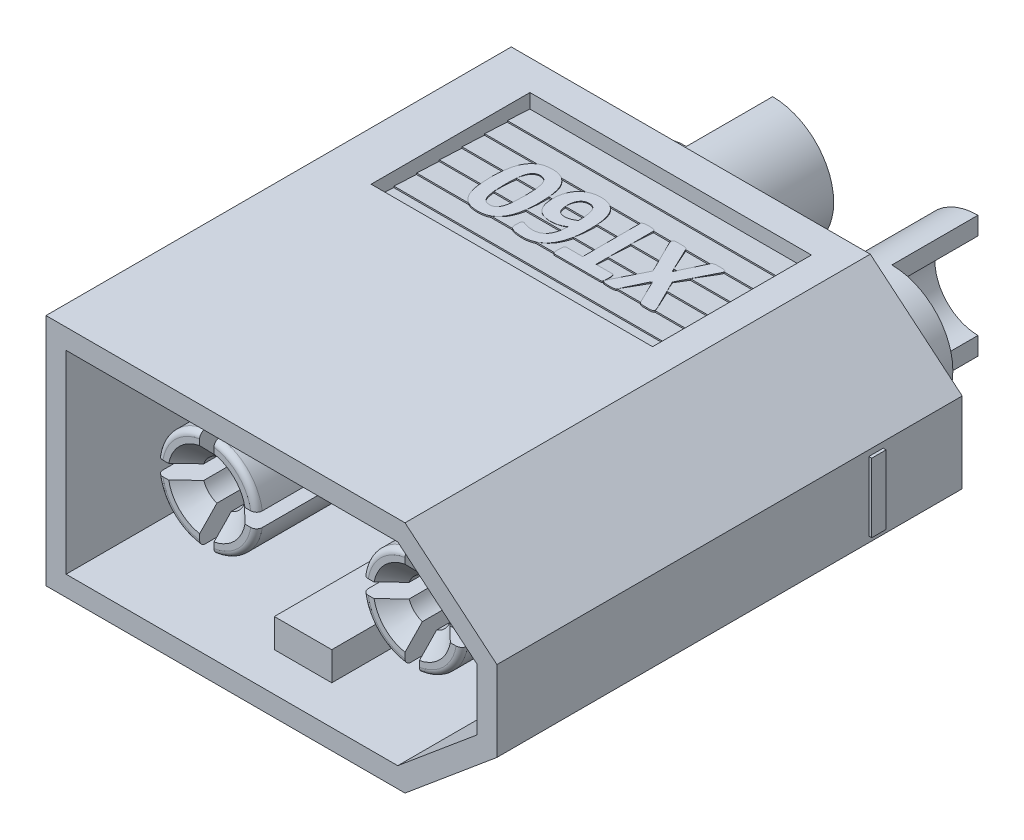
from build123d import *

# Parameters (mm, degrees)
RESSALTO_EXTRUS_O1_DEPTH       = 16.2
CORTE_EXTRUS_O1_DEPTH          = 9.3
ESBO_O3_W                      = 0.5
ESBO_O3_H                      = 2.4
RESSALTO_EXTRUS_O2_DEPTH       = 0.1
RESSALTO_EXTRUS_O2_DEPTH_BACK  = 15.8
ESBO_O4_W                      = 2.4
ESBO_O4_H                      = 0.5
RESSALTO_EXTRUS_O3_DEPTH       = 0.1
ESBO_O5_R                      = 2.925
CORTE_EXTRUS_O2_DEPTH          = 3.5
ESBO_O6_R                      = 2.125
CORTE_EXTRUS_O3_DEPTH          = 21.676934613
ESBO_O7_R                      = 2.125
RESSALTO_EXTRUS_O4_DEPTH       = 5
RESSALTO_EXTRUS_O4_DEPTH_BACK  = 7.1
FURO_DE_DI_METRO_3_0_3_1_D     = 3
FURO_DE_DI_METRO_3_0_3_1_DEPTH = 9
FURO_DE_DI_METRO_3_0_3_1_TIP   = 0.901290929
ESBO_O10_W                     = 2.125
ESBO_O10_H                     = 3
CORTE_EXTRUS_O4_DEPTH          = 28.667715844
RESSALTO_EXTRUS_O5_DEPTH       = 7.6
FILETE1_R                      = 0.2
CHANFRO1_SIZE                  = 0.6
CORTE_EXTRUS_O5_START          = -1.7
CORTE_EXTRUS_O5_DEPTH          = 9.8
RESSALTO_EXTRUS_O6_DEPTH       = 0.05
RESSALTO_EXTRUS_O7_DEPTH       = 0.05
ESBO_O15_W                     = 2
ESBO_O15_H                     = 1
RESSALTO_EXTRUS_O8_DEPTH       = 7.95
ESBO_O16_W                     = 1.1
ESBO_O16_H                     = 4.1
CORTE_EXTRUS_O6_DEPTH          = 1


with BuildPart() as part:
    # Esboço1 → Ressalto-extrusão1 (new body)
    with BuildSketch(Plane.XY):
        Polygon((0, 0), (0, 4.075), (12.5, 4.075), (15.7, 1.4), (15.7, -1.4), (12.5, -4.075), (0, -4.075), align=None)
    extrude(amount=-RESSALTO_EXTRUS_O1_DEPTH)

    # Esboço2 → Corte-extrusão1 (cut)
    with BuildSketch(Plane.XY):
        Polygon((0.7, 3.375), (0.7, -3.375), (12.245957236, -3.375), (15, -1.072792377), (15, 1.072792377), (12.245957236, 3.375), align=None)
    extrude(amount=-CORTE_EXTRUS_O1_DEPTH, mode=Mode.SUBTRACT)

    # Esboço3 → Ressalto-extrusão2 (add, two sides)
    with BuildSketch(Plane(origin=(15.7, 0, 0), x_dir=(0, 0, -1), z_dir=(1, 0, 0))) as ressalto_extrus_o2_sk:
        with Locations((13.2, 0)):
            Rectangle(ESBO_O3_W, ESBO_O3_H)
    extrude(amount=RESSALTO_EXTRUS_O2_DEPTH)
    extrude(ressalto_extrus_o2_sk.sketch, amount=-RESSALTO_EXTRUS_O2_DEPTH_BACK)

    # Esboço4 → Ressalto-extrusão3 (add)
    with BuildSketch(Plane.ZY):
        with Locations((-13.2, 0)):
            Rectangle(ESBO_O4_W, ESBO_O4_H)
    extrude(amount=RESSALTO_EXTRUS_O3_DEPTH)

    # Esboço5 → Corte-extrusão2 (cut)
    with BuildSketch(Plane(origin=(0, 0, -16.2), x_dir=(-1, 0, 0), z_dir=(0, 0, -1))):
        with Locations((-4.1, 0)):
            Circle(ESBO_O5_R)
        with Locations((-11.25, 0)):
            Circle(ESBO_O5_R)
    extrude(amount=-CORTE_EXTRUS_O2_DEPTH, mode=Mode.SUBTRACT)

    # Esboço6 → Corte-extrusão3 (cut, through all)
    with BuildSketch(Plane(origin=(0, 0, -12.7), x_dir=(-1, 0, 0), z_dir=(0, 0, -1))):
        with Locations((-11.25, 0)):
            Circle(ESBO_O6_R)
        with Locations((-4.1, 0)):
            Circle(ESBO_O6_R)
    extrude(amount=-CORTE_EXTRUS_O3_DEPTH, mode=Mode.SUBTRACT)

    # Esboço7 → Ressalto-extrusão4 (add, two sides)
    with BuildSketch(Plane(origin=(0, 0, -16.2), x_dir=(-1, 0, 0), z_dir=(0, 0, -1))) as ressalto_extrus_o4_sk:
        with Locations((-11.25, 0)):
            Circle(ESBO_O7_R)
        with Locations((-4.1, 0)):
            Circle(ESBO_O7_R)
    extrude(amount=RESSALTO_EXTRUS_O4_DEPTH)
    extrude(ressalto_extrus_o4_sk.sketch, amount=-RESSALTO_EXTRUS_O4_DEPTH_BACK)

    # Furo de diâmetro Ø3.0 (3)1
    with Locations(Plane(origin=(0, 0, -21.2), x_dir=(-1, 0, 0), z_dir=(0, 0, -1))):
        with Locations((-11.25, 0), (-4.1, 0)):
            Hole(FURO_DE_DI_METRO_3_0_3_1_D / 2, depth=FURO_DE_DI_METRO_3_0_3_1_DEPTH)
            with Locations((0, 0, -(FURO_DE_DI_METRO_3_0_3_1_DEPTH + FURO_DE_DI_METRO_3_0_3_1_TIP / 2))):  # 118° drill point
                Cone(0, FURO_DE_DI_METRO_3_0_3_1_D / 2, FURO_DE_DI_METRO_3_0_3_1_TIP, mode=Mode.SUBTRACT)

    # Esboço10 → Corte-extrusão4 (cut, through all)
    with BuildSketch(Plane(origin=(0, 4.075, 0), x_dir=(1, 0, 0), z_dir=(0, 1, 0))):
        with Locations((3.0375, 19.7)):
            Rectangle(ESBO_O10_W, ESBO_O10_H)
        with Locations((12.3125, 19.7)):
            Rectangle(ESBO_O10_W, ESBO_O10_H)
    extrude(amount=-CORTE_EXTRUS_O4_DEPTH, mode=Mode.SUBTRACT)

    # Esboço11 → Ressalto-extrusão5 (add)
    with BuildSketch(Plane.XY.offset(-9.1)):
        with BuildLine():
            Line((3.85, 1.732050808), (3.85, 0.707106781))
            ThreePointArc((3.85, 0.707106781), (3.569669914, 0.530330086), (3.392893219, 0.25))
            Line((3.392893219, 0.25), (2.367949192, 0.25))
            ThreePointArc((2.367949192, 0.25), (2.862563133, 1.237436867), (3.85, 1.732050808))
        make_face()
        with BuildLine():
            Line((4.35, 1.732050808), (4.35, 0.707106781))
            ThreePointArc((4.35, 0.707106781), (4.630330086, 0.530330086), (4.807106781, 0.25))
            Line((4.807106781, 0.25), (5.832050808, 0.25))
            ThreePointArc((5.832050808, 0.25), (5.337436867, 1.237436867), (4.35, 1.732050808))
        make_face()
        with BuildLine():
            Line((5.832050808, -0.25), (4.807106781, -0.25))
            ThreePointArc((4.807106781, -0.25), (4.630330086, -0.530330086), (4.35, -0.707106781))
            Line((4.35, -0.707106781), (4.35, -1.732050808))
            ThreePointArc((4.35, -1.732050808), (5.337436867, -1.237436867), (5.832050808, -0.25))
        make_face()
        with BuildLine():
            Line((11.957106781, 0.25), (12.982050808, 0.25))
            ThreePointArc((12.982050808, 0.25), (12.487436867, 1.237436867), (11.5, 1.732050808))
            Line((11.5, 1.732050808), (11.5, 0.707106781))
            ThreePointArc((11.5, 0.707106781), (11.780330086, 0.530330086), (11.957106781, 0.25))
        make_face()
        with BuildLine():
            Line((3.85, -0.707106781), (3.85, -1.732050808))
            ThreePointArc((3.85, -1.732050808), (2.862563133, -1.237436867), (2.367949192, -0.25))
            Line((2.367949192, -0.25), (3.392893219, -0.25))
            ThreePointArc((3.392893219, -0.25), (3.569669914, -0.530330086), (3.85, -0.707106781))
        make_face()
        with BuildLine():
            Line((11.957106781, -0.25), (12.982050808, -0.25))
            ThreePointArc((12.982050808, -0.25), (12.487436867, -1.237436867), (11.5, -1.732050808))
            Line((11.5, -1.732050808), (11.5, -0.707106781))
            ThreePointArc((11.5, -0.707106781), (11.780330086, -0.530330086), (11.957106781, -0.25))
        make_face()
        with BuildLine():
            Line((11, -0.707106781), (11, -1.732050808))
            ThreePointArc((11, -1.732050808), (10.012563133, -1.237436867), (9.517949192, -0.25))
            Line((9.517949192, -0.25), (10.542893219, -0.25))
            ThreePointArc((10.542893219, -0.25), (10.719669914, -0.530330086), (11, -0.707106781))
        make_face()
        with BuildLine():
            Line((9.517949192, 0.25), (10.542893219, 0.25))
            ThreePointArc((10.542893219, 0.25), (10.719669914, 0.530330086), (11, 0.707106781))
            Line((11, 0.707106781), (11, 1.732050808))
            ThreePointArc((11, 1.732050808), (10.012563133, 1.237436867), (9.517949192, 0.25))
        make_face()
    extrude(amount=RESSALTO_EXTRUS_O5_DEPTH)

    # Filete1
    filete1_edges = [part.edges().sort_by_distance(p)[0] for p in [
        (2.862563133, 1.237436867, -1.5),
        (2.862563133, -1.237436867, -1.5),
        (5.337436867, 1.237436867, -1.5),
        (5.337436867, -1.237436867, -1.5),
        (12.487436867, -1.237436867, -1.5),
        (12.487436867, 1.237436867, -1.5),
        (10.012563133, 1.237436867, -1.5),
        (10.012563133, -1.237436867, -1.5),
    ]]
    fillet(filete1_edges, radius=FILETE1_R)

    # Chanfro1
    chanfro1_edges = [part.edges().sort_by_distance(p)[0] for p in [
        (3.569669914, 0.530330086, -1.5),
        (3.569669914, -0.530330086, -1.5),
        (4.630330086, 0.530330086, -1.5),
        (4.630330086, -0.530330086, -1.5),
        (11.780330086, -0.530330086, -1.5),
        (11.780330086, 0.530330086, -1.5),
        (10.719669914, 0.530330086, -1.5),
        (10.719669914, -0.530330086, -1.5),
    ]]
    chamfer(chanfro1_edges, length=CHANFRO1_SIZE)

    # Esboço12 → Corte-extrusão5 (cut)
    with BuildSketch(Plane.ZY.offset(CORTE_EXTRUS_O5_START)):
        Polygon((-9.62, 4.075), (-15.15, 4.075), (-15.15, 3.575), (-14.36, 3.625), (-14.36, 3.575), (-13.57, 3.625), (-13.57, 3.575), (-12.78, 3.625), (-12.78, 3.575), (-11.99, 3.625), (-11.99, 3.575), (-11.2, 3.625), (-11.2, 3.575), (-10.41, 3.625), (-10.41, 3.575), (-9.62, 3.625), align=None)
    corte_extrus_o5 = extrude(amount=-CORTE_EXTRUS_O5_DEPTH, mode=Mode.SUBTRACT)

    # Espelhar1: Corte-extrusão5 across plane
    add(corte_extrus_o5.mirror(Plane.ZX), mode=Mode.SUBTRACT)

    # Esboço13 → Ressalto-extrusão6 (add)
    with BuildSketch(Plane(origin=(0, 3.575, 0), x_dir=(-1, 0, 0), z_dir=(0, 1, 0))):
        with BuildLine():
            add(Edge.make_bspline(
                [(-8.234641561, -13.445571688), (-8.229912114, -13.456153044), (-8.221000453, -13.476091412), (-8.208478692, -13.504296034), (-8.200539268, -13.529795764), (-8.193533814, -13.551501719), (-8.190606852, -13.570582286), (-8.190490698, -13.587635432), (-8.196029978, -13.602281593), (-8.204820877, -13.614842908), (-8.218088126, -13.624787378), (-8.235701708, -13.631860331), (-8.257272865, -13.637319606), (-8.283106651, -13.641242536), (-8.313646706, -13.643111213), (-8.34918968, -13.644848276), (-8.390224184, -13.645936797), (-8.419343109, -13.646201883), (-8.434845735, -13.646343013)],
                knots=[0, 0, 0, 0, 1.33881063, 2.522710567, 3.55823117, 4.421855077, 5.150490164, 5.783956486, 6.364012369, 6.927396487, 7.534352519, 8.24811931, 9.105929366, 10.100125022, 11.260442172, 12.637334165, 14.209750218, 16, 16, 16, 16], degree=3))
            add(Edge.make_bspline(
                [(-8.434845735, -13.646343013), (-8.45941607, -13.646007312), (-8.502710711, -13.645415784), (-8.560169388, -13.644108333), (-8.603722632, -13.638747313), (-8.636957534, -13.632327533), (-8.661538298, -13.62129635), (-8.679434231, -13.607094039), (-8.690987949, -13.588492014), (-8.696684049, -13.575151575), (-8.699705082, -13.568076225)],
                knots=[0, 0, 0, 0, 1.993677762, 3.512999033, 4.656089022, 5.552580678, 6.245508647, 6.822733668, 7.375614965, 8, 8, 8, 8], degree=3))
            Line((-8.699705082, -13.568076225), (-9.126202359, -12.674246824))
            Line((-9.126202359, -12.674246824), (-9.550998185, -13.568076225))
            add(Edge.make_bspline(
                [(-9.550998185, -13.568076225), (-9.554420482, -13.575156296), (-9.560855848, -13.588469824), (-9.572973852, -13.606730658), (-9.590400819, -13.621679404), (-9.615386313, -13.63210906), (-9.649006335, -13.638918578), (-9.69283172, -13.643968922), (-9.749683634, -13.645447394), (-9.792039641, -13.646020654), (-9.815857532, -13.646343013)],
                knots=[0, 0, 0, 0, 0.639550826, 1.202626028, 1.769676174, 2.478488857, 3.377444042, 4.554208722, 6.062341394, 8, 8, 8, 8], degree=3))
            add(Edge.make_bspline(
                [(-9.815857532, -13.646343013), (-9.830225613, -13.646198262), (-9.857264839, -13.645925857), (-9.895090158, -13.644886263), (-9.927788964, -13.643062345), (-9.955524818, -13.641330223), (-9.978882569, -13.637259243), (-9.998091686, -13.631952073), (-10.013573976, -13.624632212), (-10.025108673, -13.614746389), (-10.031959847, -13.601974011), (-10.036249426, -13.587467177), (-10.035705984, -13.570541497), (-10.032114996, -13.55148655), (-10.024728617, -13.529689189), (-10.015315431, -13.504435401), (-10.002587861, -13.475953754), (-9.992874513, -13.456125899), (-9.987704174, -13.445571688)],
                knots=[0, 0, 0, 0, 1.743948978, 3.281929376, 4.591588072, 5.719618763, 6.651354855, 7.464517483, 8.131494618, 8.716472262, 9.271430783, 9.867110125, 10.532506743, 11.302095744, 12.216435998, 13.320169609, 14.573547416, 16, 16, 16, 16], degree=3))
            Line((-9.987704174, -13.445571688), (-9.443806715, -12.364015426))
            Line((-9.443806715, -12.364015426), (-9.949137931, -11.347681488))
            add(Edge.make_bspline(
                [(-9.949137931, -11.347681488), (-9.954164514, -11.336763312), (-9.963626085, -11.316211953), (-9.975233503, -11.286701032), (-9.985307445, -11.261179787), (-9.992096331, -11.238841367), (-9.996985023, -11.21935776), (-9.996364215, -11.202215642), (-9.99249125, -11.187523225), (-9.983979844, -11.175352273), (-9.970702, -11.166484928), (-9.953902201, -11.158918283), (-9.932679067, -11.154320623), (-9.907258464, -11.150985155), (-9.876940002, -11.148999489), (-9.841213652, -11.147101222), (-9.799785428, -11.146975079), (-9.770295344, -11.146562515), (-9.754605263, -11.146343013)],
                knots=[0, 0, 0, 0, 1.381015555, 2.599495016, 3.644671344, 4.531245376, 5.285471223, 5.937655438, 6.480840598, 7.011274188, 7.602323543, 8.29283132, 9.120186307, 10.085039733, 11.239867224, 12.610244907, 14.196494385, 16, 16, 16, 16], degree=3))
            add(Edge.make_bspline(
                [(-9.754605263, -11.146343013), (-9.741558686, -11.146222788), (-9.716782999, -11.145994479), (-9.681822233, -11.147509103), (-9.651171449, -11.148360726), (-9.617850166, -11.150555873), (-9.583543752, -11.154240133), (-9.549847026, -11.161459034), (-9.524097746, -11.170598647), (-9.507151713, -11.18604274), (-9.495569929, -11.204494949), (-9.489213995, -11.217916691), (-9.485775862, -11.225176951)],
                knots=[0, 0, 0, 0, 1.305784148, 2.479707747, 3.50232644, 4.374698542, 5.823003153, 6.947851878, 7.830021634, 8.513661778, 9.195991011, 10, 10, 10, 10], degree=3))
            Line((-9.485775862, -11.225176951), (-9.087636116, -12.044142468))
            Line((-9.087636116, -12.044142468), (-8.699705082, -11.225176951))
            add(Edge.make_bspline(
                [(-8.699705082, -11.225176951), (-8.696208396, -11.217958809), (-8.689789069, -11.204707514), (-8.678987166, -11.185825159), (-8.662466375, -11.171432078), (-8.639135192, -11.161047964), (-8.607924012, -11.15443418), (-8.566580132, -11.149301561), (-8.512000017, -11.146989484), (-8.470764909, -11.146577323), (-8.447323049, -11.146343013)],
                knots=[0, 0, 0, 0, 0.679172131, 1.24684586, 1.824338574, 2.496513618, 3.384423394, 4.51265828, 6.017471582, 8, 8, 8, 8], degree=3))
            add(Edge.make_bspline(
                [(-8.447323049, -11.146343013), (-8.433523531, -11.146564201), (-8.407247474, -11.146985373), (-8.37035379, -11.147085854), (-8.338029755, -11.149027992), (-8.310179351, -11.1510601), (-8.286413928, -11.154219396), (-8.266298471, -11.159046466), (-8.250419325, -11.166827939), (-8.238191654, -11.176899845), (-8.230116772, -11.189188032), (-8.225150971, -11.20379148), (-8.224991298, -11.220836902), (-8.228948714, -11.239976481), (-8.23555094, -11.261794984), (-8.243997203, -11.287162685), (-8.254845117, -11.316345412), (-8.263479068, -11.336751762), (-8.268103448, -11.347681488)],
                knots=[0, 0, 0, 0, 1.674249213, 3.187985698, 4.474062261, 5.601505857, 6.57446085, 7.381029521, 8.09893875, 8.700896638, 9.279693563, 9.859851831, 10.548217011, 11.317405471, 12.224627673, 13.312424426, 14.560523399, 16, 16, 16, 16], degree=3))
            Line((-8.268103448, -11.347681488), (-8.773434664, -12.35834392))
            Line((-8.773434664, -12.35834392), (-8.234641561, -13.445571688))
        make_face()
        with BuildLine():
            add(Edge.make_bspline(
                [(-6.479764065, -11.364696007), (-6.479952581, -11.381903542), (-6.48029899, -11.413523441), (-6.48341703, -11.456960547), (-6.489204855, -11.492569091), (-6.495811812, -11.521038206), (-6.505603936, -11.542938637), (-6.518024204, -11.557935573), (-6.532518904, -11.56780598), (-6.543152743, -11.568899092), (-6.548389292, -11.569437387)],
                knots=[0, 0, 0, 0, 1.770192918, 3.252837809, 4.474195287, 5.478923574, 6.253187412, 6.915561504, 7.465976934, 8, 8, 8, 8], degree=3))
            Line((-6.548389292, -11.569437387), (-7.116674229, -11.569437387))
            Line((-7.116674229, -11.569437387), (-7.116674229, -13.565807623))
            add(Edge.make_bspline(
                [(-7.116674229, -13.565807623), (-7.117228597, -13.571945061), (-7.118341807, -13.584269468), (-7.127428288, -13.601786712), (-7.144220624, -13.615719697), (-7.167710509, -13.627021375), (-7.199523817, -13.634947595), (-7.239867569, -13.641788815), (-7.290547162, -13.645274662), (-7.327651728, -13.645963771), (-7.348071688, -13.646343013)],
                knots=[0, 0, 0, 0, 0.55099044, 1.106427587, 1.720983746, 2.48178517, 3.435218407, 4.660203207, 6.161991303, 8, 8, 8, 8], degree=3))
            add(Edge.make_bspline(
                [(-7.348071688, -13.646343013), (-7.368489053, -13.645949995), (-7.405777292, -13.645232225), (-7.456673966, -13.641874277), (-7.497321774, -13.634790597), (-7.529307091, -13.627297057), (-7.552592782, -13.615549041), (-7.569288598, -13.601800063), (-7.578367211, -13.584266302), (-7.579481428, -13.571944008), (-7.580036298, -13.565807623)],
                knots=[0, 0, 0, 0, 1.833840391, 3.349143282, 4.571350014, 5.538985911, 6.282919168, 6.896081612, 7.450259118, 8, 8, 8, 8], degree=3))
            Line((-7.580036298, -13.565807623), (-7.580036298, -11.569437387))
            Line((-7.580036298, -11.569437387), (-8.148321234, -11.569437387))
            add(Edge.make_bspline(
                [(-8.148321234, -11.569437387), (-8.1539353, -11.568946373), (-8.164948634, -11.567983132), (-8.179836964, -11.558248445), (-8.190916127, -11.542485604), (-8.201009403, -11.52112794), (-8.207465206, -11.492536286), (-8.21330788, -11.456972208), (-8.216406773, -11.413519579), (-8.216756267, -11.381902181), (-8.216946461, -11.364696007)],
                knots=[0, 0, 0, 0, 0.571323018, 1.120786752, 1.757624666, 2.530549763, 3.533540823, 4.752786512, 6.232867835, 8, 8, 8, 8], degree=3))
            add(Edge.make_bspline(
                [(-8.216946461, -11.364696007), (-8.216767768, -11.34692021), (-8.216440394, -11.314354056), (-8.213226949, -11.269611506), (-8.207725367, -11.233383291), (-8.20080363, -11.204762743), (-8.191287548, -11.183614648), (-8.179599375, -11.168727226), (-8.164803722, -11.159803236), (-8.153919584, -11.158779661), (-8.148321234, -11.158253176)],
                knots=[0, 0, 0, 0, 1.808148228, 3.312618493, 4.558353409, 5.533285709, 6.298922035, 6.899726023, 7.434064622, 8, 8, 8, 8], degree=3))
            Line((-8.148321234, -11.158253176), (-6.548389292, -11.158253176))
            add(Edge.make_bspline(
                [(-6.548389292, -11.158253176), (-6.543166887, -11.158822375), (-6.532660107, -11.159967528), (-6.518239485, -11.169045028), (-6.505244254, -11.183137353), (-6.49601287, -11.204856282), (-6.488944489, -11.233347393), (-6.48349821, -11.269624422), (-6.480265258, -11.314349754), (-6.479941037, -11.346918691), (-6.479764065, -11.364696007)],
                knots=[0, 0, 0, 0, 0.528901719, 1.064079353, 1.691187204, 2.458025756, 3.434488925, 4.682179932, 6.189012562, 8, 8, 8, 8], degree=3))
        make_face()
        with BuildLine():
            add(Edge.make_bspline(
                [(-4.844555354, -12.808094374), (-4.845247025, -12.838744217), (-4.846612474, -12.899251075), (-4.856275338, -12.988233606), (-4.872679949, -13.073820368), (-4.895953873, -13.155374701), (-4.925117155, -13.232653385), (-4.961282618, -13.304391043), (-5.002446968, -13.371456777), (-5.051124238, -13.432064114), (-5.104840545, -13.487492071), (-5.165252856, -13.536042443), (-5.231195633, -13.578629077), (-5.302881701, -13.615100212), (-5.380529825, -13.644444145), (-5.464224836, -13.664259535), (-5.553460591, -13.677335616), (-5.614885533, -13.678591325), (-5.646506352, -13.67923775)],
                knots=[0, 0, 0, 0, 1.10131412, 2.174140236, 3.212046795, 4.22920211, 5.218361909, 6.175388662, 7.112262148, 8.040623825, 8.963000514, 9.88076228, 10.819186251, 11.779270414, 12.766024375, 13.794191409, 14.864476351, 16, 16, 16, 16], degree=3))
            add(Edge.make_bspline(
                [(-5.646506352, -13.67923775), (-5.672045734, -13.678869754), (-5.721537896, -13.678156624), (-5.793253674, -13.670756192), (-5.859789209, -13.658257146), (-5.921656832, -13.641492467), (-5.97856069, -13.618979437), (-6.031835642, -13.592865549), (-6.08110806, -13.562363994), (-6.126246028, -13.527477715), (-6.167456271, -13.488525554), (-6.204783911, -13.445650438), (-6.237810544, -13.398487157), (-6.26758624, -13.348005903), (-6.292618909, -13.293059721), (-6.315967517, -13.235427876), (-6.33652839, -13.174283157), (-6.36003645, -13.086844775), (-6.382763535, -12.969639749), (-6.399809764, -12.820208412), (-6.408375812, -12.660363043), (-6.409376493, -12.550428328), (-6.409891107, -12.493892922)],
                knots=[0, 0, 0, 0, 0.94765967, 1.836447168, 2.671778883, 3.458266774, 4.211402354, 4.93940858, 5.657884628, 6.358212394, 7.053105983, 7.759383965, 8.46412671, 9.187383544, 9.931310937, 10.702660795, 11.494793595, 12.323735541, 14.061720359, 15.919867049, 17.901736725, 20, 20, 20, 20], degree=3))
            add(Edge.make_bspline(
                [(-6.409891107, -12.493892922), (-6.409111479, -12.444351851), (-6.40751516, -12.342914634), (-6.398296575, -12.188722943), (-6.379642121, -12.03241523), (-6.354053618, -11.903223438), (-6.326053677, -11.802303824), (-6.301145096, -11.728321145), (-6.272716985, -11.655944871), (-6.240622367, -11.585636923), (-6.204037281, -11.51831458), (-6.16258064, -11.454919209), (-6.115656325, -11.396276286), (-6.064197727, -11.341635694), (-6.007056161, -11.29202333), (-5.94441976, -11.247327276), (-5.875392712, -11.209248367), (-5.801312147, -11.174990875), (-5.720255341, -11.148506057), (-5.63233357, -11.129199885), (-5.537335641, -11.117986812), (-5.471664865, -11.116489251), (-5.437794918, -11.115716878)],
                knots=[0, 0, 0, 0, 1.551011205, 3.175754089, 4.833311519, 6.475679743, 7.292710589, 8.110576988, 8.918359717, 9.726055718, 10.528552722, 11.314823521, 12.094001482, 12.876856948, 13.661321481, 14.459397945, 15.280853931, 16.12576799, 17.011009771, 17.944382583, 18.939807688, 20, 20, 20, 20], degree=3))
            add(Edge.make_bspline(
                [(-5.437794918, -11.115716878), (-5.415464757, -11.116119973), (-5.370702147, -11.116928007), (-5.304166962, -11.124501607), (-5.239694304, -11.133367375), (-5.179993919, -11.146100086), (-5.126814374, -11.159440188), (-5.083037153, -11.175745844), (-5.049919244, -11.190634637), (-5.027663424, -11.204945901), (-5.014266481, -11.219508865), (-5.005803825, -11.234666003), (-4.999597723, -11.251019614), (-4.994372917, -11.26901591), (-4.990278959, -11.289860373), (-4.988310764, -11.314751727), (-4.987312957, -11.344646929), (-4.9870527, -11.36639614), (-4.986910163, -11.378307623)],
                knots=[0, 0, 0, 0, 1.765874355, 3.539837499, 5.29331737, 6.912486512, 8.367265213, 9.625919252, 10.602679397, 11.237403907, 11.703219776, 12.152162367, 12.602100397, 13.08489485, 13.633411172, 14.279314959, 15.057625196, 16, 16, 16, 16], degree=3))
            add(Edge.make_bspline(
                [(-4.986910163, -11.378307623), (-4.986915483, -11.396276471), (-4.986925231, -11.429206148), (-4.989441238, -11.473605088), (-4.991941835, -11.509308686), (-4.998255435, -11.536040442), (-5.005634482, -11.55664047), (-5.01768581, -11.56959271), (-5.031865418, -11.578246263), (-5.042547572, -11.57879206), (-5.048162432, -11.579078947)],
                knots=[0, 0, 0, 0, 1.876905788, 3.439613972, 4.650533844, 5.604148176, 6.312332604, 6.89971502, 7.421657351, 8, 8, 8, 8], degree=3))
            add(Edge.make_bspline(
                [(-5.048162432, -11.579078947), (-5.056152678, -11.578185642), (-5.074749872, -11.576106485), (-5.104948677, -11.565924298), (-5.141775898, -11.552592934), (-5.185598468, -11.537746817), (-5.237332484, -11.523356145), (-5.297450626, -11.510829874), (-5.367034307, -11.502088108), (-5.416591394, -11.501254624), (-5.442899274, -11.50081216)],
                knots=[0, 0, 0, 0, 0.475638614, 1.107042779, 1.880026666, 2.801778904, 3.848964285, 5.062645579, 6.440675709, 8, 8, 8, 8], degree=3))
            add(Edge.make_bspline(
                [(-5.442899274, -11.50081216), (-5.465817802, -11.501374484), (-5.510040369, -11.50245952), (-5.573600554, -11.513320605), (-5.631532579, -11.531618741), (-5.684177415, -11.55647825), (-5.730962306, -11.588558693), (-5.774066052, -11.624619941), (-5.81132997, -11.667158205), (-5.844490619, -11.713876103), (-5.872835841, -11.765396675), (-5.896989227, -11.820934395), (-5.917641849, -11.880433126), (-5.939361485, -11.965621491), (-5.95662933, -12.07883929), (-5.960455015, -12.171119195), (-5.962409256, -12.218257713)],
                knots=[0, 0, 0, 0, 0.962219322, 1.856655383, 2.698144689, 3.508120587, 4.292336159, 5.075424752, 5.862971534, 6.660705278, 7.478432318, 8.328424745, 9.202529248, 10.121421552, 12.01874047, 14, 14, 14, 14], degree=3))
            add(Edge.make_bspline(
                [(-5.962409256, -12.218257713), (-5.948705374, -12.209216367), (-5.919946224, -12.190242076), (-5.873096067, -12.163862359), (-5.82149294, -12.138826626), (-5.764644654, -12.117871226), (-5.703195854, -12.100361931), (-5.636938355, -12.086301845), (-5.5660989, -12.075934798), (-5.517235445, -12.075163254), (-5.492241379, -12.074768603)],
                knots=[0, 0, 0, 0, 0.78917907, 1.656181786, 2.583148547, 3.543818215, 4.565141387, 5.652638214, 6.799304831, 8, 8, 8, 8], degree=3))
            add(Edge.make_bspline(
                [(-5.492241379, -12.074768603), (-5.464610786, -12.075422907), (-5.411251302, -12.076686482), (-5.334103949, -12.086337051), (-5.263118639, -12.102470556), (-5.198256069, -12.125601102), (-5.138991557, -12.153616625), (-5.085650657, -12.188211663), (-5.037600875, -12.22795976), (-4.995638574, -12.273632751), (-4.958889478, -12.324344971), (-4.927177103, -12.379806858), (-4.90093147, -12.440721882), (-4.880202569, -12.506345811), (-4.864693261, -12.576467827), (-4.852544445, -12.650071848), (-4.845813158, -12.727810889), (-4.844982054, -12.780858844), (-4.844555354, -12.808094374)],
                knots=[0, 0, 0, 0, 1.185476522, 2.289361458, 3.330402215, 4.302896258, 5.239078869, 6.136970646, 7.024058495, 7.908173521, 8.79094751, 9.706658425, 10.644105674, 11.631910237, 12.65532036, 13.723663453, 14.831298352, 16, 16, 16, 16], degree=3))
        make_face()
        with BuildLine():
            add(Edge.make_bspline(
                [(-5.297708711, -12.855735027), (-5.298355421, -12.825061911), (-5.299566741, -12.767609601), (-5.311337039, -12.687156616), (-5.330852539, -12.617833028), (-5.356776743, -12.56876529), (-5.382220717, -12.535833051), (-5.404405481, -12.515072385), (-5.429147682, -12.496910224), (-5.457312983, -12.482954559), (-5.488127378, -12.471644525), (-5.521865623, -12.46281878), (-5.558874604, -12.458711163), (-5.584491022, -12.457975516), (-5.597731397, -12.457595281)],
                knots=[0, 0, 0, 0, 1.925590605, 3.606729444, 5.094508301, 6.428034127, 7.062334218, 7.700734116, 8.33023602, 8.983484412, 9.667319134, 10.390249713, 11.167967283, 12, 12, 12, 12], degree=3))
            add(Edge.make_bspline(
                [(-5.597731397, -12.457595281), (-5.613831938, -12.457981146), (-5.646202231, -12.458756929), (-5.693976134, -12.466621891), (-5.741297754, -12.477888378), (-5.787126477, -12.494006349), (-5.832242753, -12.512487237), (-5.875016027, -12.534782951), (-5.915841632, -12.558881719), (-5.941348655, -12.576902403), (-5.953901996, -12.585771325)],
                knots=[0, 0, 0, 0, 1.003605369, 2.017758243, 3.01322247, 4.035163496, 5.044917746, 6.052396451, 7.041482352, 8, 8, 8, 8], degree=3))
            add(Edge.make_bspline(
                [(-5.953901996, -12.585771325), (-5.953738845, -12.618480644), (-5.953425609, -12.681279395), (-5.949573246, -12.77115102), (-5.94273085, -12.852485608), (-5.93395734, -12.925410624), (-5.92221038, -12.990625759), (-5.907223779, -13.048428989), (-5.89141713, -13.099800439), (-5.871968607, -13.144121534), (-5.849871156, -13.181828529), (-5.825285309, -13.21370498), (-5.797816018, -13.23972106), (-5.767321144, -13.259696406), (-5.734388336, -13.274728481), (-5.698959689, -13.284662405), (-5.661295793, -13.291109954), (-5.63537983, -13.291990466), (-5.622118875, -13.292441016)],
                knots=[0, 0, 0, 0, 1.792178445, 3.440810432, 4.927313934, 6.263548764, 7.464311732, 8.554687037, 9.53417516, 10.406093985, 11.200210032, 11.923394166, 12.604947615, 13.262869107, 13.911841104, 14.580600631, 15.273706656, 16, 16, 16, 16], degree=3))
            add(Edge.make_bspline(
                [(-5.622118875, -13.292441016), (-5.609058423, -13.291927459), (-5.583757494, -13.290932587), (-5.546883676, -13.285462406), (-5.512644327, -13.275038671), (-5.470262136, -13.256338212), (-5.423274503, -13.222135383), (-5.376911642, -13.16840422), (-5.341536124, -13.102980923), (-5.316447569, -13.027712024), (-5.300226045, -12.944329052), (-5.29856505, -12.885872675), (-5.297708711, -12.855735027)],
                knots=[0, 0, 0, 0, 0.641224683, 1.242191304, 1.823353171, 2.392316502, 3.509633759, 4.640732345, 5.849129079, 7.134193297, 8.522510647, 10, 10, 10, 10], degree=3))
        make_face(mode=Mode.SUBTRACT)
        with BuildLine():
            add(Edge.make_bspline(
                [(-3.11746824, -12.386701452), (-3.118051844, -12.435106864), (-3.119187955, -12.529338284), (-3.126881805, -12.667352054), (-3.141241545, -12.797881836), (-3.159964139, -12.921294814), (-3.185411793, -13.036323407), (-3.216588532, -13.143347656), (-3.256615384, -13.240850856), (-3.302287754, -13.330230177), (-3.355612705, -13.409937458), (-3.416425654, -13.480446259), (-3.485263452, -13.540591417), (-3.561723506, -13.591334238), (-3.646311017, -13.631590004), (-3.74015479, -13.658877257), (-3.842390876, -13.676361325), (-3.913670883, -13.678255877), (-3.950612523, -13.67923775)],
                knots=[0, 0, 0, 0, 1.331714136, 2.592464548, 3.800914866, 4.943304834, 6.024741112, 7.040005629, 8.005827517, 8.920038389, 9.797084602, 10.637656394, 11.474309038, 12.303752944, 13.155259566, 14.040502508, 14.984469079, 16, 16, 16, 16], degree=3))
            add(Edge.make_bspline(
                [(-3.950612523, -13.67923775), (-3.987925423, -13.678215432), (-4.059539821, -13.676253306), (-4.161996374, -13.659539217), (-4.254654396, -13.632966746), (-4.337157484, -13.594121104), (-4.410822788, -13.545665929), (-4.474961026, -13.486179078), (-4.53278151, -13.41875554), (-4.581228314, -13.340736734), (-4.622835206, -13.253743897), (-4.656873098, -13.157554606), (-4.685449777, -13.052774236), (-4.706359958, -12.939055806), (-4.72214234, -12.816918135), (-4.732289533, -12.686857114), (-4.739518269, -12.548987571), (-4.740267624, -12.4545808), (-4.740653358, -12.405984574)],
                knots=[0, 0, 0, 0, 1.046066533, 2.007708451, 2.903737557, 3.741199507, 4.556040875, 5.366886076, 6.187145389, 7.040475504, 7.934698051, 8.887526005, 9.898691685, 10.978297228, 12.128103782, 13.351984046, 14.636924245, 16, 16, 16, 16], degree=3))
            add(Edge.make_bspline(
                [(-4.740653358, -12.405984574), (-4.740151285, -12.35795109), (-4.739170035, -12.264074476), (-4.730300275, -12.126910394), (-4.71714708, -11.996424103), (-4.697499664, -11.873091127), (-4.671655709, -11.757457308), (-4.639678789, -11.650024037), (-4.5999819, -11.551951788), (-4.554084655, -11.462484122), (-4.500832648, -11.382573185), (-4.439589167, -11.312398446), (-4.370419417, -11.252677225), (-4.294147488, -11.201897164), (-4.209537824, -11.161663757), (-4.115875262, -11.134450162), (-4.014222652, -11.116909881), (-3.943506165, -11.115001937), (-3.906941924, -11.114015426)],
                knots=[0, 0, 0, 0, 1.32239156, 2.584481369, 3.783013823, 4.932291786, 6.020825522, 7.043403636, 8.014836354, 8.929792713, 9.807554109, 10.652234463, 11.486148566, 12.316268837, 13.168469815, 14.054434623, 14.994037682, 16, 16, 16, 16], degree=3))
            add(Edge.make_bspline(
                [(-3.906941924, -11.114015426), (-3.869648343, -11.115132161), (-3.798100753, -11.117274611), (-3.695364398, -11.132740235), (-3.602916537, -11.160657993), (-3.519828368, -11.198807711), (-3.446399956, -11.248082215), (-3.380463468, -11.305890952), (-3.323973019, -11.374768583), (-3.275075651, -11.452425518), (-3.233792053, -11.539406053), (-3.199177976, -11.635341355), (-3.171737987, -11.74036778), (-3.151071585, -11.85419546), (-3.136434424, -11.976230899), (-3.124752055, -12.106144019), (-3.118911693, -12.243914513), (-3.117957533, -12.338300328), (-3.11746824, -12.386701452)],
                knots=[0, 0, 0, 0, 1.045902831, 2.006560538, 2.903970151, 3.746105489, 4.56081934, 5.375878205, 6.196660228, 7.049856803, 7.94393941, 8.891632579, 9.906387228, 10.984846666, 12.133800561, 13.352654929, 14.642439237, 16, 16, 16, 16], degree=3))
        make_face()
        with BuildLine():
            add(Edge.make_bspline(
                [(-3.58253176, -12.41165608), (-3.582632227, -12.383108616), (-3.582826527, -12.327898802), (-3.584556338, -12.24754172), (-3.587332422, -12.172477342), (-3.591190326, -12.102313588), (-3.596600678, -12.037126681), (-3.601590621, -11.976094404), (-3.609976057, -11.919850481), (-3.620687665, -11.85280788), (-3.636758403, -11.77877234), (-3.661367241, -11.701166165), (-3.690688913, -11.63747601), (-3.727222675, -11.588002598), (-3.769498616, -11.551521367), (-3.817649774, -11.527810607), (-3.870510753, -11.514711141), (-3.907246375, -11.513025845), (-3.926225045, -11.512155172)],
                knots=[0, 0, 0, 0, 1.284431786, 2.484047002, 3.616142059, 4.664071033, 5.645250234, 6.559356666, 7.418250505, 8.202740236, 9.614323635, 10.822083543, 11.86068477, 12.753813116, 13.56848039, 14.348298709, 15.146684002, 16, 16, 16, 16], degree=3))
            add(Edge.make_bspline(
                [(-3.926225045, -11.512155172), (-3.94272449, -11.512773786), (-3.974738283, -11.513974078), (-4.020479085, -11.524198551), (-4.061709768, -11.541583746), (-4.0986431, -11.565592514), (-4.130700128, -11.597385469), (-4.160082476, -11.635008682), (-4.184506144, -11.680358905), (-4.206235997, -11.731800528), (-4.223990686, -11.79006314), (-4.239358744, -11.854624979), (-4.250824065, -11.926150865), (-4.260591563, -12.004068284), (-4.266898638, -12.088886585), (-4.272215001, -12.180199726), (-4.274814622, -12.278361062), (-4.275325751, -12.346054678), (-4.275589837, -12.381029946)],
                knots=[0, 0, 0, 0, 0.762118583, 1.478735069, 2.152336062, 2.821329334, 3.501193893, 4.230120737, 5.02038063, 5.874145257, 6.808384398, 7.832217387, 8.939929293, 10.155058802, 11.461419548, 12.870631504, 14.383148819, 16, 16, 16, 16], degree=3))
            add(Edge.make_bspline(
                [(-4.275589837, -12.381029946), (-4.275474704, -12.423193699), (-4.275254708, -12.503760971), (-4.27082077, -12.618892187), (-4.265835085, -12.722786573), (-4.257067114, -12.815628103), (-4.246923143, -12.898487727), (-4.232443531, -12.97184427), (-4.21653428, -13.03664949), (-4.197393466, -13.092768137), (-4.175152616, -13.140509635), (-4.150328431, -13.180969635), (-4.121951294, -13.213546827), (-4.090574604, -13.23907326), (-4.055402457, -13.256441996), (-4.017820774, -13.269923514), (-3.976579034, -13.27696989), (-3.948176802, -13.278198671), (-3.933598004, -13.278829401)],
                knots=[0, 0, 0, 0, 1.898873998, 3.628403222, 5.188934062, 6.582708822, 7.827907354, 8.94675174, 9.948352832, 10.831595324, 11.612452879, 12.316456424, 12.962066015, 13.549833112, 14.124880791, 14.720002925, 15.342980538, 16, 16, 16, 16], degree=3))
            add(Edge.make_bspline(
                [(-3.933598004, -13.278829401), (-3.911923762, -13.277656011), (-3.870436452, -13.275409991), (-3.811642651, -13.257531529), (-3.761118676, -13.226329249), (-3.717280064, -13.183429289), (-3.68113515, -13.127888058), (-3.652214417, -13.060264127), (-3.627852002, -12.981576269), (-3.609965107, -12.890833613), (-3.595569955, -12.788623314), (-3.587896668, -12.673973624), (-3.583553211, -12.547053145), (-3.582882644, -12.458166989), (-3.58253176, -12.41165608)],
                knots=[0, 0, 0, 0, 0.751197133, 1.437888758, 2.106068794, 2.792541115, 3.549301373, 4.389082058, 5.337144767, 6.40224806, 7.594198163, 8.916220199, 10.386369622, 12, 12, 12, 12], degree=3))
        make_face(mode=Mode.SUBTRACT)
    extrude(amount=RESSALTO_EXTRUS_O6_DEPTH)

    # Esboço14 → Ressalto-extrusão7 (add)
    with BuildSketch(Plane(origin=(0, -3.575, 0), x_dir=(-1, 0, 0), z_dir=(0, 1, 0))):
        with BuildLine():
            add(Edge.make_bspline(
                [(-5.47488657, -10.871252269), (-5.474722568, -10.878993167), (-5.474314418, -10.89825791), (-5.470884957, -10.931172474), (-5.466829831, -10.971685719), (-5.459930441, -11.016863984), (-5.451262344, -11.065433416), (-5.439136975, -11.114971543), (-5.426514751, -11.164127603), (-5.410206937, -11.208864298), (-5.392278374, -11.249022453), (-5.369361189, -11.279316016), (-5.345140954, -11.304036801), (-5.324811163, -11.307061216), (-5.315426497, -11.30845735)],
                knots=[0, 0, 0, 0, 0.569387536, 1.417032566, 2.432701303, 3.564649302, 4.778070122, 6.060490265, 7.316356391, 8.506785177, 9.565983581, 10.524288402, 11.31878, 12, 12, 12, 12], degree=3))
            Line((-5.315426497, -11.30845735), (-4.562295826, -11.30845735))
            Line((-4.562295826, -11.30845735), (-4.080921053, -13.943666062))
            add(Edge.make_bspline(
                [(-4.080921053, -13.943666062), (-4.078049987, -13.951824904), (-4.072202689, -13.968441448), (-4.05586764, -13.990959212), (-4.030744426, -14.009757156), (-3.996352227, -14.024194158), (-3.95204821, -14.034677522), (-3.897339588, -14.043995403), (-3.829448199, -14.048564048), (-3.779722068, -14.049471679), (-3.752268603, -14.049972777)],
                knots=[0, 0, 0, 0, 0.562754615, 1.146122955, 1.784880109, 2.58721322, 3.563293576, 4.752564911, 6.207112733, 8, 8, 8, 8], degree=3))
            add(Edge.make_bspline(
                [(-3.752268603, -14.049972777), (-3.725319414, -14.04944941), (-3.676350759, -14.048498413), (-3.610134329, -14.044196717), (-3.55845671, -14.034841166), (-3.519068606, -14.025036677), (-3.491672885, -14.009604884), (-3.473878659, -13.990620428), (-3.466967167, -13.967237653), (-3.468497633, -13.951660697), (-3.469283122, -13.943666062)],
                knots=[0, 0, 0, 0, 1.911196729, 3.472784822, 4.694253329, 5.634626498, 6.332407189, 6.896531254, 7.433661504, 8, 8, 8, 8], degree=3))
            Line((-3.469283122, -13.943666062), (-3.951406534, -11.30845735))
            Line((-3.951406534, -11.30845735), (-3.205013612, -11.30845735))
            add(Edge.make_bspline(
                [(-3.205013612, -11.30845735), (-3.194598819, -11.307559173), (-3.174588058, -11.305833435), (-3.15470698, -11.279246766), (-3.146397167, -11.245222766), (-3.145577263, -11.219443584), (-3.145122505, -11.205145191)],
                knots=[0, 0, 0, 0, 0.889821815, 1.709684739, 2.729679269, 4, 4, 4, 4], degree=3))
            add(Edge.make_bspline(
                [(-3.145122505, -11.205145191), (-3.145333103, -11.196909509), (-3.145837751, -11.177174675), (-3.147851926, -11.143381166), (-3.153644019, -11.102551586), (-3.15973239, -11.056186324), (-3.16989381, -11.007163531), (-3.180433909, -10.95644602), (-3.194392868, -10.907661424), (-3.210208799, -10.862343227), (-3.230057237, -10.824015907), (-3.251462939, -10.793381697), (-3.275721726, -10.770406953), (-3.295506399, -10.767176264), (-3.304582577, -10.765694192)],
                knots=[0, 0, 0, 0, 0.603562236, 1.446291891, 2.478015879, 3.623340615, 4.871035952, 6.144054999, 7.417205306, 8.585498042, 9.656636744, 10.559854985, 11.339336372, 12, 12, 12, 12], degree=3))
            Line((-3.304582577, -10.765694192), (-5.417241379, -10.765694192))
            add(Edge.make_bspline(
                [(-5.417241379, -10.765694192), (-5.426021044, -10.766945731), (-5.444266447, -10.769546607), (-5.462772826, -10.795156836), (-5.473521221, -10.829335295), (-5.474394038, -10.856131249), (-5.47488657, -10.871252269)],
                knots=[0, 0, 0, 0, 0.769617577, 1.599375678, 2.64532208, 4, 4, 4, 4], degree=3))
        make_face()
        with BuildLine():
            add(Edge.make_bspline(
                [(-7.798362069, -11.113811252), (-7.798231436, -11.12354962), (-7.797936183, -11.145560039), (-7.794465971, -11.181476908), (-7.790313331, -11.222977063), (-7.783664337, -11.267707758), (-7.774653403, -11.314164887), (-7.763685503, -11.360118712), (-7.751300331, -11.40432106), (-7.736734567, -11.44388848), (-7.720521764, -11.478755331), (-7.701702289, -11.504992196), (-7.682684947, -11.526498187), (-7.666446234, -11.529464114), (-7.659115245, -11.530803085)],
                knots=[0, 0, 0, 0, 0.763872462, 1.726485752, 2.829243498, 4.036555683, 5.273047091, 6.541071871, 7.743292575, 8.870803578, 9.851566093, 10.737008226, 11.42982069, 12, 12, 12, 12], degree=3))
            add(Edge.make_bspline(
                [(-7.659115245, -11.530803085), (-7.65283626, -11.529998195), (-7.638714668, -11.528187979), (-7.61586719, -11.520166043), (-7.589829713, -11.506229454), (-7.547956763, -11.47931538), (-7.486049388, -11.43786025), (-7.413466614, -11.399050951), (-7.346580208, -11.364680104), (-7.288112116, -11.340410348), (-7.224393037, -11.317272037), (-7.15540878, -11.295268055), (-7.080033832, -11.276391372), (-6.998056912, -11.26192493), (-6.909093834, -11.255113346), (-6.847848408, -11.253759055), (-6.816147913, -11.253058076)],
                knots=[0, 0, 0, 0, 0.294208217, 0.661681512, 1.11903447, 1.667173581, 2.979109855, 4.586359241, 5.495809246, 6.479993016, 7.531377717, 8.65232186, 9.850138254, 11.14732419, 12.523461389, 14, 14, 14, 14], degree=3))
            add(Edge.make_bspline(
                [(-6.816147913, -11.253058076), (-6.783914554, -11.253672562), (-6.72071138, -11.254877446), (-6.62805261, -11.267447938), (-6.539341479, -11.286744906), (-6.454645068, -11.313667908), (-6.374431935, -11.347896709), (-6.297217204, -11.386738834), (-6.224204171, -11.43262809), (-6.154348061, -11.483594655), (-6.088546738, -11.539676116), (-6.027008208, -11.600712178), (-5.968997948, -11.66604551), (-5.897480148, -11.75970525), (-5.819093264, -11.886545906), (-5.739307366, -12.047653354), (-5.678228989, -12.218418241), (-5.634247617, -12.393921884), (-5.608362457, -12.571642907), (-5.604512585, -12.69011603), (-5.602604356, -12.748838475)],
                knots=[0, 0, 0, 0, 0.813513377, 1.595137151, 2.35655918, 3.1039003, 3.835371584, 4.556839838, 5.284255452, 6.010250331, 6.738865941, 7.465188928, 8.197311374, 8.943456002, 10.438364047, 11.954570311, 13.47549657, 15.008437719, 16.517200777, 18, 18, 18, 18], degree=3))
            add(Edge.make_bspline(
                [(-5.602604356, -12.748838475), (-5.603064912, -12.780311888), (-5.603959175, -12.841423805), (-5.614125497, -12.929990517), (-5.629323538, -13.012805109), (-5.651940944, -13.089465993), (-5.68026386, -13.1599327), (-5.714255761, -13.224517652), (-5.754015167, -13.282945325), (-5.799119365, -13.33605798), (-5.850347922, -13.38226989), (-5.906121261, -13.423234365), (-5.967246566, -13.457715317), (-6.033186871, -13.486261151), (-6.10409737, -13.507805355), (-6.179023981, -13.523295018), (-6.257883844, -13.533486925), (-6.311782474, -13.534428933), (-6.339264973, -13.534909256)],
                knots=[0, 0, 0, 0, 1.232735546, 2.393602282, 3.488684494, 4.528357374, 5.519821941, 6.460306148, 7.382462978, 8.284013572, 9.183865529, 10.079670315, 10.990559277, 11.927886292, 12.889832997, 13.889031302, 14.923633251, 16, 16, 16, 16], degree=3))
            add(Edge.make_bspline(
                [(-6.339264973, -13.534909256), (-6.377027456, -13.533506858), (-6.452506187, -13.530703778), (-6.563741996, -13.511425602), (-6.671058275, -13.481423579), (-6.737175319, -13.449541974), (-6.769732305, -13.433843013)],
                knots=[0, 0, 0, 0, 1.015261146, 2.029279186, 3.029588664, 4, 4, 4, 4], degree=3))
            Line((-6.769732305, -13.433843013), (-6.908979129, -12.678466425))
            Line((-6.908979129, -12.678466425), (-6.343756806, -12.678466425))
            add(Edge.make_bspline(
                [(-6.343756806, -12.678466425), (-6.335164404, -12.677321308), (-6.317618312, -12.674982925), (-6.296067736, -12.653577266), (-6.284965811, -12.619276195), (-6.284268032, -12.592715085), (-6.283865699, -12.577400181)],
                knots=[0, 0, 0, 0, 0.773973524, 1.580490691, 2.604932126, 4, 4, 4, 4], degree=3))
            add(Edge.make_bspline(
                [(-6.283865699, -12.577400181), (-6.284315342, -12.567665135), (-6.285331057, -12.545674295), (-6.288217923, -12.509930305), (-6.293383343, -12.469449311), (-6.301032991, -12.426319962), (-6.309915153, -12.38186711), (-6.319933966, -12.33716483), (-6.332798725, -12.29493849), (-6.348613271, -12.257110718), (-6.366132069, -12.224677918), (-6.386109031, -12.199120047), (-6.408309104, -12.179546125), (-6.426067271, -12.17670501), (-6.434342105, -12.175381125)],
                knots=[0, 0, 0, 0, 0.776210759, 1.753409867, 2.855448116, 4.025307541, 5.241528985, 6.466167287, 7.67325879, 8.751192984, 9.730007966, 10.592987336, 11.344369447, 12, 12, 12, 12], degree=3))
            Line((-6.434342105, -12.175381125), (-7.446501815, -12.175381125))
            add(Edge.make_bspline(
                [(-7.446501815, -12.175381125), (-7.458281137, -12.176162985), (-7.480542422, -12.177640591), (-7.512182321, -12.187065125), (-7.537263759, -12.205843261), (-7.556880541, -12.230823437), (-7.569216295, -12.262274922), (-7.575736004, -12.29908225), (-7.576407768, -12.341565778), (-7.571764022, -12.371320511), (-7.569278584, -12.387245917)],
                knots=[0, 0, 0, 0, 0.983500601, 1.858679748, 2.707743233, 3.552717286, 4.476279504, 5.492474932, 6.657915964, 8, 8, 8, 8], degree=3))
            Line((-7.569278584, -12.387245917), (-7.328216878, -13.696615245))
            add(Edge.make_bspline(
                [(-7.328216878, -13.696615245), (-7.324956707, -13.711393174), (-7.318806238, -13.739272442), (-7.306513474, -13.778092387), (-7.289453042, -13.811496688), (-7.275325549, -13.83079308), (-7.268325771, -13.840353902)],
                knots=[0, 0, 0, 0, 1.154287523, 2.177618469, 3.09706093, 4, 4, 4, 4], degree=3))
            add(Edge.make_bspline(
                [(-7.268325771, -13.840353902), (-7.262685109, -13.84570628), (-7.249654328, -13.858071079), (-7.2244059, -13.87633787), (-7.189814459, -13.893967587), (-7.131044189, -13.922681047), (-7.041721134, -13.957414978), (-6.919300623, -13.997191344), (-6.778895092, -14.034943639), (-6.624086828, -14.064449053), (-6.459679456, -14.087005935), (-6.34732931, -14.089260791), (-6.290603448, -14.090399274)],
                knots=[0, 0, 0, 0, 0.227973833, 0.52665391, 0.90987875, 1.364944221, 2.445550802, 3.716353017, 5.140312564, 6.706492918, 8.337100265, 10, 10, 10, 10], degree=3))
            add(Edge.make_bspline(
                [(-6.290603448, -14.090399274), (-6.23841193, -14.089396055), (-6.137296956, -14.087452435), (-5.990080076, -14.072370679), (-5.85260554, -14.047200089), (-5.724320274, -14.012310037), (-5.606219565, -13.966477753), (-5.497695906, -13.910977078), (-5.398927738, -13.845790515), (-5.310634366, -13.770166582), (-5.232313837, -13.685321572), (-5.164785107, -13.590585485), (-5.10588328, -13.487789014), (-5.058107179, -13.375402027), (-5.02024484, -13.254091091), (-4.995216693, -13.123706441), (-4.977680628, -12.984882903), (-4.976073431, -12.889392506), (-4.975245009, -12.840172414)],
                knots=[0, 0, 0, 0, 1.209618431, 2.343494514, 3.425843007, 4.446081447, 5.420371625, 6.356873684, 7.266516126, 8.156807203, 9.045141842, 9.936109147, 10.848010934, 11.786030204, 12.761195717, 13.787841972, 14.859753156, 16, 16, 16, 16], degree=3))
            add(Edge.make_bspline(
                [(-4.975245009, -12.840172414), (-4.976102924, -12.794742377), (-4.977811216, -12.704281497), (-4.987297518, -12.569260873), (-5.005093295, -12.435973987), (-5.027690341, -12.304089184), (-5.058583395, -12.174687305), (-5.096106933, -12.048343678), (-5.139280246, -11.924811308), (-5.190562956, -11.805413386), (-5.247061538, -11.689064845), (-5.311037722, -11.577578627), (-5.380604674, -11.470044772), (-5.457092356, -11.367701588), (-5.539117164, -11.270001639), (-5.628294533, -11.179478965), (-5.723861749, -11.09585496), (-5.825946974, -11.019647393), (-5.93360611, -10.949641992), (-6.047682865, -10.888416804), (-6.167417473, -10.834815557), (-6.293297698, -10.789952642), (-6.425391054, -10.753963025), (-6.563468978, -10.727509168), (-6.707767594, -10.712687575), (-6.805883791, -10.71060588), (-6.855825771, -10.709546279)],
                knots=[0, 0, 0, 0, 1.029039829, 2.049037502, 3.063445244, 4.073497931, 5.078366394, 6.074470398, 7.057646765, 8.040238121, 9.01592932, 9.985462294, 10.949576625, 11.914932658, 12.877422086, 13.836620146, 14.789938829, 15.750767359, 16.71962466, 17.695757752, 18.679940823, 19.688205034, 20.719276166, 21.777878753, 22.868921344, 24, 24, 24, 24], degree=3))
            add(Edge.make_bspline(
                [(-6.855825771, -10.709546279), (-6.910813682, -10.710896434), (-7.017991602, -10.713528043), (-7.172597505, -10.736366832), (-7.314427863, -10.767818145), (-7.440811445, -10.8072715), (-7.551170986, -10.848188301), (-7.628999826, -10.889138714), (-7.680658917, -10.920892314), (-7.710986274, -10.940679235), (-7.734832935, -10.957812905), (-7.756208953, -10.977311882), (-7.776587639, -11.00083214), (-7.789888401, -11.034255081), (-7.797650908, -11.07200431), (-7.798110771, -11.099038246), (-7.798362069, -11.113811252)],
                knots=[0, 0, 0, 0, 2.094202926, 4.081848358, 5.943580953, 7.625004438, 9.124278352, 10.421520585, 10.967870217, 11.434697698, 11.801761051, 12.084492439, 12.537457955, 12.971981325, 13.438227331, 14, 14, 14, 14], degree=3))
        make_face()
        with BuildLine():
            Line((-8.937490926, -12.794505445), (-8.72862069, -13.946660617))
            add(Edge.make_bspline(
                [(-8.72862069, -13.946660617), (-8.725749485, -13.954818949), (-8.719901903, -13.971434454), (-8.703569111, -13.993960487), (-8.678435631, -14.012720826), (-8.644152215, -14.027326751), (-8.599200773, -14.036933995), (-8.543986992, -14.045307752), (-8.476130734, -14.049230517), (-8.426920753, -14.049710104), (-8.39996824, -14.049972777)],
                knots=[0, 0, 0, 0, 0.5633487, 1.147332887, 1.78676436, 2.589944472, 3.563099597, 4.783310014, 6.238205357, 8, 8, 8, 8], degree=3))
            add(Edge.make_bspline(
                [(-8.39996824, -14.049972777), (-8.373020595, -14.049696705), (-8.324317293, -14.049197751), (-8.258384882, -14.04556617), (-8.206957126, -14.03698562), (-8.167302542, -14.027917502), (-8.139490314, -14.012807089), (-8.121585905, -13.993604523), (-8.114664822, -13.970234933), (-8.116196598, -13.954656176), (-8.116982759, -13.946660617)],
                knots=[0, 0, 0, 0, 1.913620462, 3.458544765, 4.678870315, 5.615793161, 6.329934673, 6.894895157, 7.432821802, 8, 8, 8, 8], degree=3))
            Line((-8.116982759, -13.946660617), (-8.325852995, -12.794505445))
            Line((-8.325852995, -12.794505445), (-7.834745917, -11.012745009))
            add(Edge.make_bspline(
                [(-7.834745917, -11.012745009), (-7.827810493, -10.986337989), (-7.815589671, -10.939806511), (-7.80186445, -10.877723351), (-7.801905237, -10.827568599), (-7.820021317, -10.795153243), (-7.843081547, -10.779616697), (-7.864506142, -10.768849231), (-7.891954948, -10.762825082), (-7.924170757, -10.757560938), (-7.963197339, -10.753904586), (-8.008913651, -10.752065639), (-8.062072758, -10.750463421), (-8.099762661, -10.750144062), (-8.119977314, -10.749972777)],
                knots=[0, 0, 0, 0, 1.850203908, 3.260221068, 4.311110186, 5.175579991, 5.635708458, 6.180402494, 6.791674956, 7.52857969, 8.395363126, 9.445298932, 10.629808227, 12, 12, 12, 12], degree=3))
            add(Edge.make_bspline(
                [(-8.119977314, -10.749972777), (-8.148938661, -10.749882778), (-8.200154562, -10.749723621), (-8.268289341, -10.753760169), (-8.320754223, -10.758533475), (-8.360290273, -10.768867485), (-8.390512153, -10.783390236), (-8.410060342, -10.806884772), (-8.421367962, -10.836199503), (-8.426908193, -10.857468063), (-8.429913793, -10.869006352)],
                knots=[0, 0, 0, 0, 1.880321679, 3.325203435, 4.4350216, 5.292265217, 5.974010189, 6.571771058, 7.225179452, 8, 8, 8, 8], degree=3))
            Line((-8.429913793, -10.869006352), (-8.631297641, -11.655077132))
            add(Edge.make_bspline(
                [(-8.631297641, -11.655077132), (-8.642513468, -11.700939677), (-8.664403729, -11.790450958), (-8.69281617, -11.923853628), (-8.719298719, -12.056209968), (-8.73341824, -12.145131613), (-8.740598911, -12.190353902)],
                knots=[0, 0, 0, 0, 1.03664038, 2.02324159, 2.994693142, 4, 4, 4, 4], degree=3))
            Line((-8.740598911, -12.190353902), (-8.745090744, -12.190353902))
            add(Edge.make_bspline(
                [(-8.745090744, -12.190353902), (-8.766865878, -12.145343796), (-8.810270833, -12.055623951), (-8.878775009, -11.922510215), (-8.950599061, -11.790276037), (-9.001627543, -11.703348999), (-9.027327586, -11.659568966)],
                knots=[0, 0, 0, 0, 0.997704726, 1.988751446, 2.987052468, 4, 4, 4, 4], degree=3))
            Line((-9.027327586, -11.659568966), (-9.507205082, -10.861519964))
            add(Edge.make_bspline(
                [(-9.507205082, -10.861519964), (-9.513161427, -10.851350471), (-9.52440473, -10.832154357), (-9.545394644, -10.806852928), (-9.571395017, -10.785992287), (-9.606228748, -10.771236431), (-9.650590806, -10.760122976), (-9.707954032, -10.754206823), (-9.781655426, -10.750730738), (-9.836848074, -10.750246514), (-9.868049002, -10.749972777)],
                knots=[0, 0, 0, 0, 0.705367449, 1.331464076, 1.959699991, 2.68244787, 3.57830166, 4.693034009, 6.130540755, 8, 8, 8, 8], degree=3))
            add(Edge.make_bspline(
                [(-9.868049002, -10.749972777), (-9.889259528, -10.750186495), (-9.928941152, -10.75058633), (-9.984387403, -10.751670401), (-10.031536173, -10.754941451), (-10.071146294, -10.758075207), (-10.103768923, -10.764018555), (-10.13018298, -10.771769725), (-10.150865238, -10.782401712), (-10.165687902, -10.795970594), (-10.17483653, -10.812868221), (-10.176453731, -10.832651986), (-10.173452944, -10.855096131), (-10.157651127, -10.890496634), (-10.128611579, -10.943606318), (-10.101386709, -10.987679142), (-10.085902904, -11.012745009)],
                knots=[0, 0, 0, 0, 1.626643513, 3.043199312, 4.251173266, 5.250816831, 6.087769487, 6.789816082, 7.3548853, 7.855713405, 8.309353638, 8.791177203, 9.351365224, 10.030074411, 11.742154494, 14, 14, 14, 14], degree=3))
            Line((-10.085902904, -11.012745009), (-8.937490926, -12.794505445))
        make_face()
    extrude(amount=-RESSALTO_EXTRUS_O7_DEPTH)

    # Esboço15 → Ressalto-extrusão8 (add)
    with BuildSketch(Plane.XY.offset(-9.3)):
        with Locations((7.6, -2.875)):
            Rectangle(ESBO_O15_W, ESBO_O15_H)
    extrude(amount=RESSALTO_EXTRUS_O8_DEPTH)

    # Esboço16 → Corte-extrusão6 (cut)
    with BuildSketch(Plane.XY.offset(-9.3)):
        with Locations((7.6, -0.125)):
            Rectangle(ESBO_O16_W, ESBO_O16_H)
    extrude(amount=-CORTE_EXTRUS_O6_DEPTH, mode=Mode.SUBTRACT)


solid = part.part
